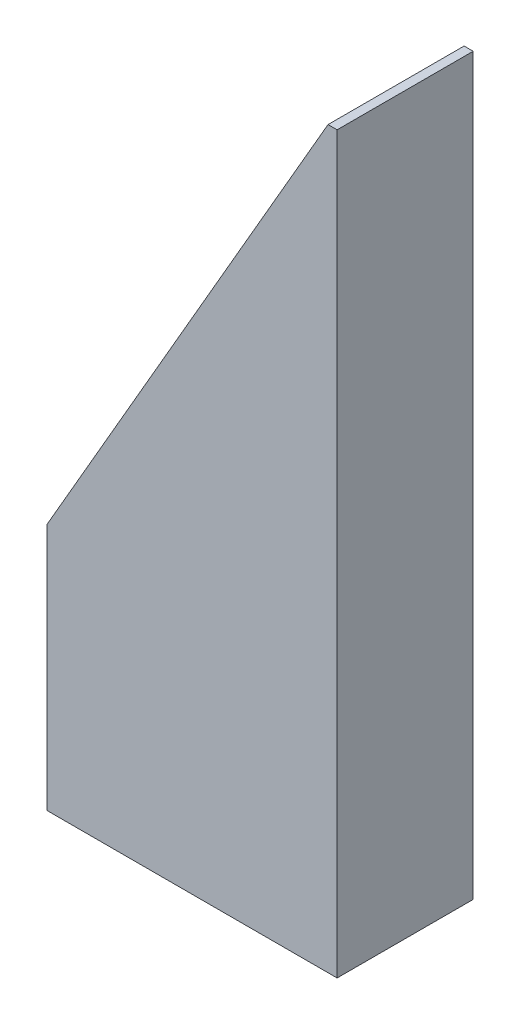
from build123d import *

# Parameters (mm, degrees)
BOSS_EXTRUDE1_DEPTH = 15


with BuildPart() as part:
    # Sketch1 → Boss-Extrude1 (new body)
    with BuildSketch(Plane.XY):
        Polygon((0, 27.276424965), (31, 80.97), (32, 80.97), (32, 0), (0, 0), align=None)
    extrude(amount=BOSS_EXTRUDE1_DEPTH)


solid = part.part
